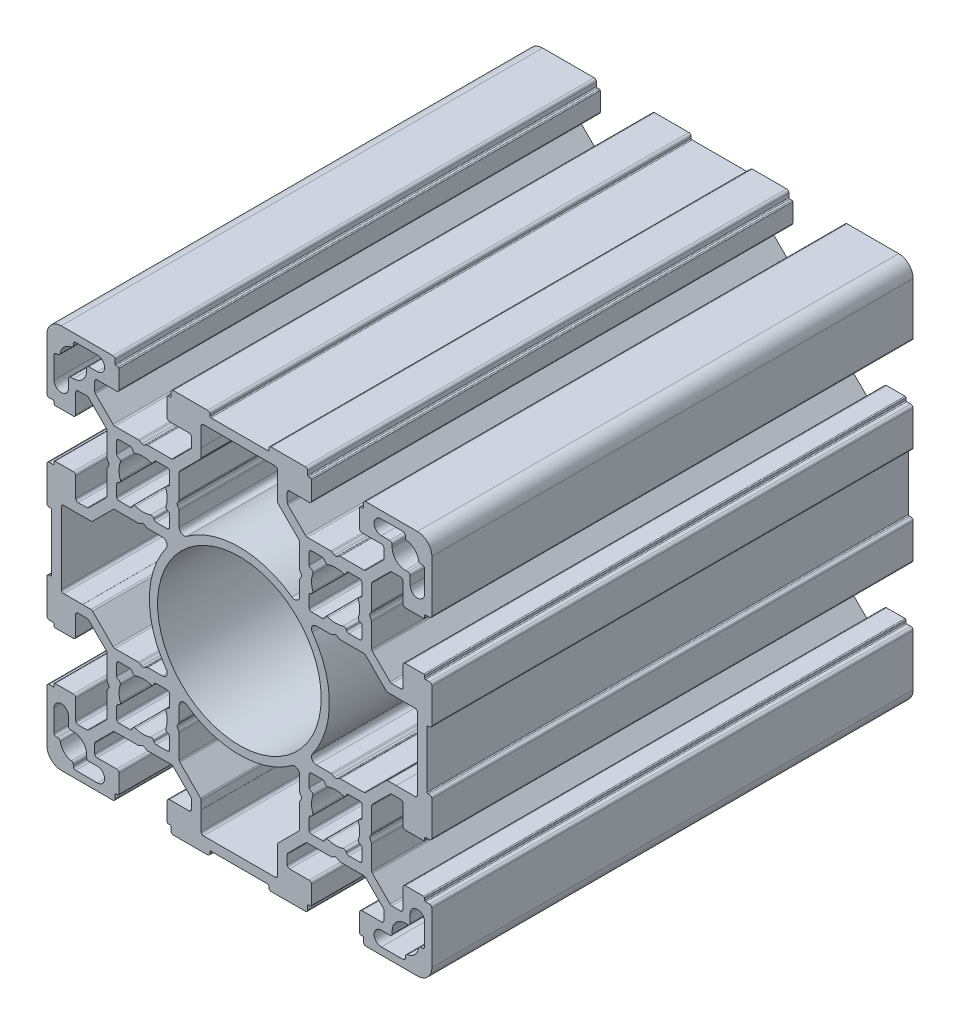
from build123d import *

# Parameters (mm, degrees)
SKETCH_1_R      = 17
EXTRUDE_2_DEPTH = 100


with BuildPart() as part:
    # Эскиз1 → Бобышка-Вытянуть2 (new body)
    with BuildSketch(Plane.XY):
        with BuildLine():
            Line((19.10095497, 46.510086301), (19.60095497, 46.798761436))
            ThreePointArc((19.60095497, 46.798761436), (19.721545448, 46.848711647), (19.85095497, 46.865748734))
            Line((19.85095497, 46.865748734), (24.729634627, 46.865748734))
            ThreePointArc((24.729634627, 46.865748734), (24.920976343, 46.903808968), (25.083188017, 47.012195343))
            Line((25.083188017, 47.012195343), (28.754508361, 50.683515687))
            ThreePointArc((28.754508361, 50.683515687), (28.862894737, 50.845727361), (28.90095497, 51.037069077))
            Line((28.90095497, 51.037069077), (28.90095497, 52.865748734))
            ThreePointArc((28.90095497, 52.865748734), (28.754508361, 53.219302125), (28.40095497, 53.365748734))
            Line((28.40095497, 53.365748734), (24.35095497, 53.365748734))
            ThreePointArc((24.35095497, 53.365748734), (23.99740158, 53.512195343), (23.85095497, 53.865748734))
            Line((23.85095497, 53.865748734), (23.85095497, 57.665748734))
            ThreePointArc((23.85095497, 57.665748734), (23.909533614, 57.80717009), (24.05095497, 57.865748734))
            Line((24.05095497, 57.865748734), (24.45095497, 57.865748734))
            ThreePointArc((24.45095497, 57.865748734), (24.592376327, 57.924327378), (24.65095497, 58.065748734))
            Line((24.65095497, 58.065748734), (24.65095497, 58.865748734))
            ThreePointArc((24.65095497, 58.865748734), (24.79740158, 59.219302125), (25.15095497, 59.365748734))
            Line((25.15095497, 59.365748734), (32.24095497, 59.365748734))
            ThreePointArc((32.24095497, 59.365748734), (32.594508361, 59.219302125), (32.74095497, 58.865748734))
            Line((32.74095497, 58.865748734), (32.74095497, 58.565748734))
            ThreePointArc((32.74095497, 58.565748734), (32.799533614, 58.424327378), (32.94095497, 58.365748734))
            Line((32.94095497, 58.365748734), (44.76095497, 58.365748734))
            ThreePointArc((44.76095497, 58.365748734), (44.902376327, 58.424327378), (44.96095497, 58.565748734))
            Line((44.96095497, 58.565748734), (44.96095497, 58.865748734))
            ThreePointArc((44.96095497, 58.865748734), (45.10740158, 59.219302125), (45.46095497, 59.365748734))
            Line((45.46095497, 59.365748734), (52.55095497, 59.365748734))
            ThreePointArc((52.55095497, 59.365748734), (52.904508361, 59.219302125), (53.05095497, 58.865748734))
            Line((53.05095497, 58.865748734), (53.05095497, 58.065748734))
            ThreePointArc((53.05095497, 58.065748734), (53.109533614, 57.924327378), (53.25095497, 57.865748734))
            Line((53.25095497, 57.865748734), (53.65095497, 57.865748734))
            ThreePointArc((53.65095497, 57.865748734), (53.792376327, 57.80717009), (53.85095497, 57.665748734))
            Line((53.85095497, 57.665748734), (53.85095497, 53.865748734))
            ThreePointArc((53.85095497, 53.865748734), (53.704508361, 53.512195343), (53.35095497, 53.365748734))
            Line((53.35095497, 53.365748734), (49.30095497, 53.365748734))
            ThreePointArc((49.30095497, 53.365748734), (48.94740158, 53.219302125), (48.80095497, 52.865748734))
            Line((48.80095497, 52.865748734), (48.80095497, 51.037069077))
            ThreePointArc((48.80095497, 51.037069077), (48.839015204, 50.845727361), (48.94740158, 50.683515687))
            Line((48.94740158, 50.683515687), (52.618721923, 47.012195343))
            ThreePointArc((52.618721923, 47.012195343), (52.780933598, 46.903808968), (52.972275314, 46.865748734))
            Line((52.972275314, 46.865748734), (57.85095497, 46.865748734))
            ThreePointArc((57.85095497, 46.865748734), (57.980364493, 46.848711647), (58.10095497, 46.798761436))
            Line((58.10095497, 46.798761436), (58.60095497, 46.510086301))
            ThreePointArc((58.60095497, 46.510086301), (58.85095497, 46.443099003), (59.10095497, 46.510086301))
            Line((59.10095497, 46.510086301), (59.60095497, 46.798761436))
            ThreePointArc((59.60095497, 46.798761436), (59.721545448, 46.848711647), (59.85095497, 46.865748734))
            Line((59.85095497, 46.865748734), (64.729634627, 46.865748734))
            ThreePointArc((64.729634627, 46.865748734), (64.920976343, 46.903808968), (65.083188017, 47.012195343))
            Line((65.083188017, 47.012195343), (68.754508361, 50.683515687))
            ThreePointArc((68.754508361, 50.683515687), (68.862894737, 50.845727361), (68.90095497, 51.037069077))
            Line((68.90095497, 51.037069077), (68.90095497, 52.865748734))
            ThreePointArc((68.90095497, 52.865748734), (68.754508361, 53.219302125), (68.40095497, 53.365748734))
            Line((68.40095497, 53.365748734), (64.35095497, 53.365748734))
            ThreePointArc((64.35095497, 53.365748734), (63.99740158, 53.512195343), (63.85095497, 53.865748734))
            Line((63.85095497, 53.865748734), (63.85095497, 57.665748734))
            ThreePointArc((63.85095497, 57.665748734), (63.909533614, 57.80717009), (64.05095497, 57.865748734))
            Line((64.05095497, 57.865748734), (64.45095497, 57.865748734))
            ThreePointArc((64.45095497, 57.865748734), (64.592376327, 57.924327378), (64.65095497, 58.065748734))
            Line((64.65095497, 58.065748734), (64.65095497, 58.865748734))
            ThreePointArc((64.65095497, 58.865748734), (64.79740158, 59.219302125), (65.15095497, 59.365748734))
            Line((65.15095497, 59.365748734), (75.85095497, 59.365748734))
            ThreePointArc((75.85095497, 59.365748734), (77.972275314, 58.487069077), (78.85095497, 56.365748734))
            Line((78.85095497, 56.365748734), (78.85095497, 45.665748734))
            ThreePointArc((78.85095497, 45.665748734), (78.704508361, 45.312195343), (78.35095497, 45.165748734))
            Line((78.35095497, 45.165748734), (77.55095497, 45.165748734))
            ThreePointArc((77.55095497, 45.165748734), (77.409533614, 45.10717009), (77.35095497, 44.965748734))
            Line((77.35095497, 44.965748734), (77.35095497, 44.565748734))
            ThreePointArc((77.35095497, 44.565748734), (77.292376327, 44.424327378), (77.15095497, 44.365748734))
            Line((77.15095497, 44.365748734), (73.35095497, 44.365748734))
            ThreePointArc((73.35095497, 44.365748734), (72.99740158, 44.512195343), (72.85095497, 44.865748734))
            Line((72.85095497, 44.865748734), (72.85095497, 48.915748734))
            ThreePointArc((72.85095497, 48.915748734), (72.704508361, 49.269302125), (72.35095497, 49.415748734))
            Line((72.35095497, 49.415748734), (70.522275314, 49.415748734))
            ThreePointArc((70.522275314, 49.415748734), (70.330933598, 49.3776885), (70.168721923, 49.269302125))
            Line((70.168721923, 49.269302125), (66.49740158, 45.597981781))
            ThreePointArc((66.49740158, 45.597981781), (66.389015204, 45.435770107), (66.35095497, 45.24442839))
            Line((66.35095497, 45.24442839), (66.35095497, 40.365748734))
            ThreePointArc((66.35095497, 40.365748734), (66.333917884, 40.236339211), (66.283967672, 40.115748734))
            Line((66.283967672, 40.115748734), (65.995292538, 39.615748734))
            ThreePointArc((65.995292538, 39.615748734), (65.92830524, 39.365748734), (65.995292538, 39.115748734))
            Line((65.995292538, 39.115748734), (66.283967672, 38.615748734))
            ThreePointArc((66.283967672, 38.615748734), (66.333917884, 38.495158256), (66.35095497, 38.365748734))
            Line((66.35095497, 38.365748734), (66.35095497, 33.487069077))
            ThreePointArc((66.35095497, 33.487069077), (66.389015204, 33.295727361), (66.49740158, 33.133515687))
            Line((66.49740158, 33.133515687), (70.168721923, 29.462195343))
            ThreePointArc((70.168721923, 29.462195343), (70.330933598, 29.353808968), (70.522275314, 29.315748734))
            Line((70.522275314, 29.315748734), (72.35095497, 29.315748734))
            ThreePointArc((72.35095497, 29.315748734), (72.704508361, 29.462195343), (72.85095497, 29.815748734))
            Line((72.85095497, 29.815748734), (72.85095497, 33.865748734))
            ThreePointArc((72.85095497, 33.865748734), (72.99740158, 34.219302125), (73.35095497, 34.365748734))
            Line((73.35095497, 34.365748734), (77.15095497, 34.365748734))
            ThreePointArc((77.15095497, 34.365748734), (77.292376327, 34.30717009), (77.35095497, 34.165748734))
            Line((77.35095497, 34.165748734), (77.35095497, 33.765748734))
            ThreePointArc((77.35095497, 33.765748734), (77.409533614, 33.624327378), (77.55095497, 33.565748734))
            Line((77.55095497, 33.565748734), (78.35095497, 33.565748734))
            ThreePointArc((78.35095497, 33.565748734), (78.704508361, 33.419302125), (78.85095497, 33.065748734))
            Line((78.85095497, 33.065748734), (78.85095497, 25.975748734))
            ThreePointArc((78.85095497, 25.975748734), (78.704508361, 25.622195343), (78.35095497, 25.475748734))
            Line((78.35095497, 25.475748734), (78.05095497, 25.475748734))
            ThreePointArc((78.05095497, 25.475748734), (77.909533614, 25.41717009), (77.85095497, 25.275748734))
            Line((77.85095497, 25.275748734), (77.85095497, 13.455748734))
            ThreePointArc((77.85095497, 13.455748734), (77.909533614, 13.314327378), (78.05095497, 13.255748734))
            Line((78.05095497, 13.255748734), (78.35095497, 13.255748734))
            ThreePointArc((78.35095497, 13.255748734), (78.704508361, 13.109302125), (78.85095497, 12.755748734))
            Line((78.85095497, 12.755748734), (78.85095497, 5.665748734))
            ThreePointArc((78.85095497, 5.665748734), (78.704508361, 5.312195343), (78.35095497, 5.165748734))
            Line((78.35095497, 5.165748734), (77.55095497, 5.165748734))
            ThreePointArc((77.55095497, 5.165748734), (77.409533614, 5.10717009), (77.35095497, 4.965748734))
            Line((77.35095497, 4.965748734), (77.35095497, 4.565748734))
            ThreePointArc((77.35095497, 4.565748734), (77.292376327, 4.424327378), (77.15095497, 4.365748734))
            Line((77.15095497, 4.365748734), (73.35095497, 4.365748734))
            ThreePointArc((73.35095497, 4.365748734), (72.99740158, 4.512195343), (72.85095497, 4.865748734))
            Line((72.85095497, 4.865748734), (72.85095497, 8.915748734))
            ThreePointArc((72.85095497, 8.915748734), (72.704508361, 9.269302125), (72.35095497, 9.415748734))
            Line((72.35095497, 9.415748734), (70.522275314, 9.415748734))
            ThreePointArc((70.522275314, 9.415748734), (70.330933598, 9.3776885), (70.168721923, 9.269302125))
            Line((70.168721923, 9.269302125), (66.49740158, 5.597981781))
            ThreePointArc((66.49740158, 5.597981781), (66.389015204, 5.435770107), (66.35095497, 5.24442839))
            Line((66.35095497, 5.24442839), (66.35095497, 0.365748734))
            ThreePointArc((66.35095497, 0.365748734), (66.333917884, 0.236339211), (66.283967672, 0.115748734))
            Line((66.283967672, 0.115748734), (65.995292538, -0.384251266))
            ThreePointArc((65.995292538, -0.384251266), (65.92830524, -0.634251266), (65.995292538, -0.884251266))
            Line((65.995292538, -0.884251266), (66.283967672, -1.384251266))
            ThreePointArc((66.283967672, -1.384251266), (66.333917884, -1.504841744), (66.35095497, -1.634251266))
            Line((66.35095497, -1.634251266), (66.35095497, -6.512930923))
            ThreePointArc((66.35095497, -6.512930923), (66.389015204, -6.704272639), (66.49740158, -6.866484313))
            Line((66.49740158, -6.866484313), (70.168721923, -10.537804657))
            ThreePointArc((70.168721923, -10.537804657), (70.330933598, -10.646191032), (70.522275314, -10.684251266))
            Line((70.522275314, -10.684251266), (72.35095497, -10.684251266))
            ThreePointArc((72.35095497, -10.684251266), (72.704508361, -10.537804657), (72.85095497, -10.184251266))
            Line((72.85095497, -10.184251266), (72.85095497, -6.134251266))
            ThreePointArc((72.85095497, -6.134251266), (72.99740158, -5.780697875), (73.35095497, -5.634251266))
            Line((73.35095497, -5.634251266), (77.15095497, -5.634251266))
            ThreePointArc((77.15095497, -5.634251266), (77.292376327, -5.69282991), (77.35095497, -5.834251266))
            Line((77.35095497, -5.834251266), (77.35095497, -6.234251266))
            ThreePointArc((77.35095497, -6.234251266), (77.409533614, -6.375672622), (77.55095497, -6.434251266))
            Line((77.55095497, -6.434251266), (78.35095497, -6.434251266))
            ThreePointArc((78.35095497, -6.434251266), (78.704508361, -6.580697875), (78.85095497, -6.934251266))
            Line((78.85095497, -6.934251266), (78.85095497, -17.634251266))
            ThreePointArc((78.85095497, -17.634251266), (77.972275314, -19.75557161), (75.85095497, -20.634251266))
            Line((75.85095497, -20.634251266), (65.15095497, -20.634251266))
            ThreePointArc((65.15095497, -20.634251266), (64.79740158, -20.487804657), (64.65095497, -20.134251266))
            Line((64.65095497, -20.134251266), (64.65095497, -19.334251266))
            ThreePointArc((64.65095497, -19.334251266), (64.592376327, -19.19282991), (64.45095497, -19.134251266))
            Line((64.45095497, -19.134251266), (64.05095497, -19.134251266))
            ThreePointArc((64.05095497, -19.134251266), (63.909533614, -19.075672622), (63.85095497, -18.934251266))
            Line((63.85095497, -18.934251266), (63.85095497, -15.134251266))
            ThreePointArc((63.85095497, -15.134251266), (63.99740158, -14.780697875), (64.35095497, -14.634251266))
            Line((64.35095497, -14.634251266), (68.40095497, -14.634251266))
            ThreePointArc((68.40095497, -14.634251266), (68.754508361, -14.487804657), (68.90095497, -14.134251266))
            Line((68.90095497, -14.134251266), (68.90095497, -12.30557161))
            ThreePointArc((68.90095497, -12.30557161), (68.862894737, -12.114229893), (68.754508361, -11.952018219))
            Line((68.754508361, -11.952018219), (65.083188017, -8.280697875))
            ThreePointArc((65.083188017, -8.280697875), (64.920976343, -8.1723115), (64.729634627, -8.134251266))
            Line((64.729634627, -8.134251266), (59.85095497, -8.134251266))
            ThreePointArc((59.85095497, -8.134251266), (59.721545448, -8.117214179), (59.60095497, -8.067263968))
            Line((59.60095497, -8.067263968), (59.10095497, -7.778588833))
            ThreePointArc((59.10095497, -7.778588833), (58.85095497, -7.711601535), (58.60095497, -7.778588833))
            Line((58.60095497, -7.778588833), (58.10095497, -8.067263968))
            ThreePointArc((58.10095497, -8.067263968), (57.980364493, -8.117214179), (57.85095497, -8.134251266))
            Line((57.85095497, -8.134251266), (52.972275314, -8.134251266))
            ThreePointArc((52.972275314, -8.134251266), (52.780933598, -8.1723115), (52.618721923, -8.280697875))
            Line((52.618721923, -8.280697875), (48.94740158, -11.952018219))
            ThreePointArc((48.94740158, -11.952018219), (48.839015204, -12.114229893), (48.80095497, -12.30557161))
            Line((48.80095497, -12.30557161), (48.80095497, -14.134251266))
            ThreePointArc((48.80095497, -14.134251266), (48.94740158, -14.487804657), (49.30095497, -14.634251266))
            Line((49.30095497, -14.634251266), (53.35095497, -14.634251266))
            ThreePointArc((53.35095497, -14.634251266), (53.704508361, -14.780697875), (53.85095497, -15.134251266))
            Line((53.85095497, -15.134251266), (53.85095497, -18.934251266))
            ThreePointArc((53.85095497, -18.934251266), (53.792376327, -19.075672622), (53.65095497, -19.134251266))
            Line((53.65095497, -19.134251266), (53.25095497, -19.134251266))
            ThreePointArc((53.25095497, -19.134251266), (53.109533614, -19.19282991), (53.05095497, -19.334251266))
            Line((53.05095497, -19.334251266), (53.05095497, -20.134251266))
            ThreePointArc((53.05095497, -20.134251266), (52.904508361, -20.487804657), (52.55095497, -20.634251266))
            Line((52.55095497, -20.634251266), (45.46095497, -20.634251266))
            ThreePointArc((45.46095497, -20.634251266), (45.10740158, -20.487804657), (44.96095497, -20.134251266))
            Line((44.96095497, -20.134251266), (44.96095497, -19.834251266))
            ThreePointArc((44.96095497, -19.834251266), (44.902376327, -19.69282991), (44.76095497, -19.634251266))
            Line((44.76095497, -19.634251266), (32.94095497, -19.634251266))
            ThreePointArc((32.94095497, -19.634251266), (32.799533614, -19.69282991), (32.74095497, -19.834251266))
            Line((32.74095497, -19.834251266), (32.74095497, -20.134251266))
            ThreePointArc((32.74095497, -20.134251266), (32.594508361, -20.487804657), (32.24095497, -20.634251266))
            Line((32.24095497, -20.634251266), (25.15095497, -20.634251266))
            ThreePointArc((25.15095497, -20.634251266), (24.79740158, -20.487804657), (24.65095497, -20.134251266))
            Line((24.65095497, -20.134251266), (24.65095497, -19.334251266))
            ThreePointArc((24.65095497, -19.334251266), (24.592376327, -19.19282991), (24.45095497, -19.134251266))
            Line((24.45095497, -19.134251266), (24.05095497, -19.134251266))
            ThreePointArc((24.05095497, -19.134251266), (23.909533614, -19.075672622), (23.85095497, -18.934251266))
            Line((23.85095497, -18.934251266), (23.85095497, -15.134251266))
            ThreePointArc((23.85095497, -15.134251266), (23.99740158, -14.780697875), (24.35095497, -14.634251266))
            Line((24.35095497, -14.634251266), (28.40095497, -14.634251266))
            ThreePointArc((28.40095497, -14.634251266), (28.754508361, -14.487804657), (28.90095497, -14.134251266))
            Line((28.90095497, -14.134251266), (28.90095497, -12.30557161))
            ThreePointArc((28.90095497, -12.30557161), (28.862894737, -12.114229893), (28.754508361, -11.952018219))
            Line((28.754508361, -11.952018219), (25.083188017, -8.280697875))
            ThreePointArc((25.083188017, -8.280697875), (24.920976343, -8.1723115), (24.729634627, -8.134251266))
            Line((24.729634627, -8.134251266), (19.85095497, -8.134251266))
            ThreePointArc((19.85095497, -8.134251266), (19.721545448, -8.117214179), (19.60095497, -8.067263968))
            Line((19.60095497, -8.067263968), (19.10095497, -7.778588833))
            ThreePointArc((19.10095497, -7.778588833), (18.85095497, -7.711601535), (18.60095497, -7.778588833))
            Line((18.60095497, -7.778588833), (18.10095497, -8.067263968))
            ThreePointArc((18.10095497, -8.067263968), (17.980364493, -8.117214179), (17.85095497, -8.134251266))
            Line((17.85095497, -8.134251266), (12.972275314, -8.134251266))
            ThreePointArc((12.972275314, -8.134251266), (12.780933598, -8.1723115), (12.618721923, -8.280697875))
            Line((12.618721923, -8.280697875), (8.94740158, -11.952018219))
            ThreePointArc((8.94740158, -11.952018219), (8.839015204, -12.114229893), (8.80095497, -12.30557161))
            Line((8.80095497, -12.30557161), (8.80095497, -14.134251266))
            ThreePointArc((8.80095497, -14.134251266), (8.94740158, -14.487804657), (9.30095497, -14.634251266))
            Line((9.30095497, -14.634251266), (13.35095497, -14.634251266))
            ThreePointArc((13.35095497, -14.634251266), (13.704508361, -14.780697875), (13.85095497, -15.134251266))
            Line((13.85095497, -15.134251266), (13.85095497, -18.934251266))
            ThreePointArc((13.85095497, -18.934251266), (13.792376327, -19.075672622), (13.65095497, -19.134251266))
            Line((13.65095497, -19.134251266), (13.25095497, -19.134251266))
            ThreePointArc((13.25095497, -19.134251266), (13.109533614, -19.19282991), (13.05095497, -19.334251266))
            Line((13.05095497, -19.334251266), (13.05095497, -20.134251266))
            ThreePointArc((13.05095497, -20.134251266), (12.904508361, -20.487804657), (12.55095497, -20.634251266))
            Line((12.55095497, -20.634251266), (1.85095497, -20.634251266))
            ThreePointArc((1.85095497, -20.634251266), (-0.270365373, -19.75557161), (-1.14904503, -17.634251266))
            Line((-1.14904503, -17.634251266), (-1.14904503, -6.934251266))
            ThreePointArc((-1.14904503, -6.934251266), (-1.00259842, -6.580697875), (-0.64904503, -6.434251266))
            Line((-0.64904503, -6.434251266), (0.15095497, -6.434251266))
            ThreePointArc((0.15095497, -6.434251266), (0.292376327, -6.375672622), (0.35095497, -6.234251266))
            Line((0.35095497, -6.234251266), (0.35095497, -5.834251266))
            ThreePointArc((0.35095497, -5.834251266), (0.409533614, -5.69282991), (0.55095497, -5.634251266))
            Line((0.55095497, -5.634251266), (4.35095497, -5.634251266))
            ThreePointArc((4.35095497, -5.634251266), (4.704508361, -5.780697875), (4.85095497, -6.134251266))
            Line((4.85095497, -6.134251266), (4.85095497, -10.184251266))
            ThreePointArc((4.85095497, -10.184251266), (4.99740158, -10.537804657), (5.35095497, -10.684251266))
            Line((5.35095497, -10.684251266), (7.179634627, -10.684251266))
            ThreePointArc((7.179634627, -10.684251266), (7.370976343, -10.646191032), (7.533188017, -10.537804657))
            Line((7.533188017, -10.537804657), (11.204508361, -6.866484313))
            ThreePointArc((11.204508361, -6.866484313), (11.312894737, -6.704272639), (11.35095497, -6.512930923))
            Line((11.35095497, -6.512930923), (11.35095497, -1.634251266))
            ThreePointArc((11.35095497, -1.634251266), (11.367992057, -1.504841744), (11.417942269, -1.384251266))
            Line((11.417942269, -1.384251266), (11.706617403, -0.884251266))
            ThreePointArc((11.706617403, -0.884251266), (11.773604701, -0.634251266), (11.706617403, -0.384251266))
            Line((11.706617403, -0.384251266), (11.417942269, 0.115748734))
            ThreePointArc((11.417942269, 0.115748734), (11.367992057, 0.236339211), (11.35095497, 0.365748734))
            Line((11.35095497, 0.365748734), (11.35095497, 5.24442839))
            ThreePointArc((11.35095497, 5.24442839), (11.312894737, 5.435770107), (11.204508361, 5.597981781))
            Line((11.204508361, 5.597981781), (7.533188017, 9.269302125))
            ThreePointArc((7.533188017, 9.269302125), (7.370976343, 9.3776885), (7.179634627, 9.415748734))
            Line((7.179634627, 9.415748734), (5.35095497, 9.415748734))
            ThreePointArc((5.35095497, 9.415748734), (4.99740158, 9.269302125), (4.85095497, 8.915748734))
            Line((4.85095497, 8.915748734), (4.85095497, 4.865748734))
            ThreePointArc((4.85095497, 4.865748734), (4.704508361, 4.512195343), (4.35095497, 4.365748734))
            Line((4.35095497, 4.365748734), (0.55095497, 4.365748734))
            ThreePointArc((0.55095497, 4.365748734), (0.409533614, 4.424327378), (0.35095497, 4.565748734))
            Line((0.35095497, 4.565748734), (0.35095497, 4.965748734))
            ThreePointArc((0.35095497, 4.965748734), (0.292376327, 5.10717009), (0.15095497, 5.165748734))
            Line((0.15095497, 5.165748734), (-0.64904503, 5.165748734))
            ThreePointArc((-0.64904503, 5.165748734), (-1.00259842, 5.312195343), (-1.14904503, 5.665748734))
            Line((-1.14904503, 5.665748734), (-1.14904503, 12.755748734))
            ThreePointArc((-1.14904503, 12.755748734), (-1.00259842, 13.109302125), (-0.64904503, 13.255748734))
            Line((-0.64904503, 13.255748734), (-0.34904503, 13.255748734))
            ThreePointArc((-0.34904503, 13.255748734), (-0.207623673, 13.314327378), (-0.14904503, 13.455748734))
            Line((-0.14904503, 13.455748734), (-0.14904503, 25.275748734))
            ThreePointArc((-0.14904503, 25.275748734), (-0.207623673, 25.41717009), (-0.34904503, 25.475748734))
            Line((-0.34904503, 25.475748734), (-0.64904503, 25.475748734))
            ThreePointArc((-0.64904503, 25.475748734), (-1.00259842, 25.622195343), (-1.14904503, 25.975748734))
            Line((-1.14904503, 25.975748734), (-1.14904503, 33.065748734))
            ThreePointArc((-1.14904503, 33.065748734), (-1.00259842, 33.419302125), (-0.64904503, 33.565748734))
            Line((-0.64904503, 33.565748734), (0.15095497, 33.565748734))
            ThreePointArc((0.15095497, 33.565748734), (0.292376327, 33.624327378), (0.35095497, 33.765748734))
            Line((0.35095497, 33.765748734), (0.35095497, 34.165748734))
            ThreePointArc((0.35095497, 34.165748734), (0.409533614, 34.30717009), (0.55095497, 34.365748734))
            Line((0.55095497, 34.365748734), (4.35095497, 34.365748734))
            ThreePointArc((4.35095497, 34.365748734), (4.704508361, 34.219302125), (4.85095497, 33.865748734))
            Line((4.85095497, 33.865748734), (4.85095497, 29.815748734))
            ThreePointArc((4.85095497, 29.815748734), (4.99740158, 29.462195343), (5.35095497, 29.315748734))
            Line((5.35095497, 29.315748734), (7.179634627, 29.315748734))
            ThreePointArc((7.179634627, 29.315748734), (7.370976343, 29.353808968), (7.533188017, 29.462195343))
            Line((7.533188017, 29.462195343), (11.204508361, 33.133515687))
            ThreePointArc((11.204508361, 33.133515687), (11.312894737, 33.295727361), (11.35095497, 33.487069077))
            Line((11.35095497, 33.487069077), (11.35095497, 38.365748734))
            ThreePointArc((11.35095497, 38.365748734), (11.367992057, 38.495158256), (11.417942269, 38.615748734))
            Line((11.417942269, 38.615748734), (11.706617403, 39.115748734))
            ThreePointArc((11.706617403, 39.115748734), (11.773604701, 39.365748734), (11.706617403, 39.615748734))
            Line((11.706617403, 39.615748734), (11.417942269, 40.115748734))
            ThreePointArc((11.417942269, 40.115748734), (11.367992057, 40.236339211), (11.35095497, 40.365748734))
            Line((11.35095497, 40.365748734), (11.35095497, 45.24442839))
            ThreePointArc((11.35095497, 45.24442839), (11.312894737, 45.435770107), (11.204508361, 45.597981781))
            Line((11.204508361, 45.597981781), (7.533188017, 49.269302125))
            ThreePointArc((7.533188017, 49.269302125), (7.370976343, 49.3776885), (7.179634627, 49.415748734))
            Line((7.179634627, 49.415748734), (5.35095497, 49.415748734))
            ThreePointArc((5.35095497, 49.415748734), (4.99740158, 49.269302125), (4.85095497, 48.915748734))
            Line((4.85095497, 48.915748734), (4.85095497, 44.865748734))
            ThreePointArc((4.85095497, 44.865748734), (4.704508361, 44.512195343), (4.35095497, 44.365748734))
            Line((4.35095497, 44.365748734), (0.55095497, 44.365748734))
            ThreePointArc((0.55095497, 44.365748734), (0.409533614, 44.424327378), (0.35095497, 44.565748734))
            Line((0.35095497, 44.565748734), (0.35095497, 44.965748734))
            ThreePointArc((0.35095497, 44.965748734), (0.292376327, 45.10717009), (0.15095497, 45.165748734))
            Line((0.15095497, 45.165748734), (-0.64904503, 45.165748734))
            ThreePointArc((-0.64904503, 45.165748734), (-1.00259842, 45.312195343), (-1.14904503, 45.665748734))
            Line((-1.14904503, 45.665748734), (-1.14904503, 56.365748734))
            ThreePointArc((-1.14904503, 56.365748734), (-0.270365373, 58.487069077), (1.85095497, 59.365748734))
            Line((1.85095497, 59.365748734), (12.55095497, 59.365748734))
            ThreePointArc((12.55095497, 59.365748734), (12.904508361, 59.219302125), (13.05095497, 58.865748734))
            Line((13.05095497, 58.865748734), (13.05095497, 58.065748734))
            ThreePointArc((13.05095497, 58.065748734), (13.109533614, 57.924327378), (13.25095497, 57.865748734))
            Line((13.25095497, 57.865748734), (13.65095497, 57.865748734))
            ThreePointArc((13.65095497, 57.865748734), (13.792376327, 57.80717009), (13.85095497, 57.665748734))
            Line((13.85095497, 57.665748734), (13.85095497, 53.865748734))
            ThreePointArc((13.85095497, 53.865748734), (13.704508361, 53.512195343), (13.35095497, 53.365748734))
            Line((13.35095497, 53.365748734), (9.30095497, 53.365748734))
            ThreePointArc((9.30095497, 53.365748734), (8.94740158, 53.219302125), (8.80095497, 52.865748734))
            Line((8.80095497, 52.865748734), (8.80095497, 51.037069077))
            ThreePointArc((8.80095497, 51.037069077), (8.839015204, 50.845727361), (8.94740158, 50.683515687))
            Line((8.94740158, 50.683515687), (12.618721923, 47.012195343))
            ThreePointArc((12.618721923, 47.012195343), (12.780933598, 46.903808968), (12.972275314, 46.865748734))
            Line((12.972275314, 46.865748734), (17.85095497, 46.865748734))
            ThreePointArc((17.85095497, 46.865748734), (17.980364493, 46.848711647), (18.10095497, 46.798761436))
            Line((18.10095497, 46.798761436), (18.60095497, 46.510086301))
            ThreePointArc((18.60095497, 46.510086301), (18.85095497, 46.443099003), (19.10095497, 46.510086301))
        make_face()
        with Locations((38.85095497, 19.365748734)):
            Circle(SKETCH_1_R, mode=Mode.SUBTRACT)
        with BuildLine():
            Line((4.35095497, 57.365748734), (4.35095497, 57.077056879))
            ThreePointArc((4.35095497, 57.077056879), (4.230732233, 56.751835061), (3.927878047, 56.583009472))
            ThreePointArc((3.927878047, 56.583009472), (2.406411322, 55.810292382), (1.633694233, 54.288825657))
            ThreePointArc((1.633694233, 54.288825657), (1.464868644, 53.985971471), (1.139646826, 53.865748734))
            Line((1.139646826, 53.865748734), (0.85095497, 53.865748734))
            ThreePointArc((0.85095497, 53.865748734), (0.49740158, 53.719302125), (0.35095497, 53.365748734))
            Line((0.35095497, 53.365748734), (0.35095497, 48.865748734))
            ThreePointArc((0.35095497, 48.865748734), (1.85095497, 47.365748734), (3.35095497, 48.865748734))
            Line((3.35095497, 48.865748734), (3.35095497, 50.615748734))
            ThreePointArc((3.35095497, 50.615748734), (3.49740158, 50.969302125), (3.85095497, 51.115748734))
            Line((3.85095497, 51.115748734), (4.35095497, 51.115748734))
            ThreePointArc((4.35095497, 51.115748734), (6.295498619, 51.921205086), (7.10095497, 53.865748734))
            Line((7.10095497, 53.865748734), (7.10095497, 54.365748734))
            ThreePointArc((7.10095497, 54.365748734), (7.24740158, 54.719302125), (7.60095497, 54.865748734))
            Line((7.60095497, 54.865748734), (9.35095497, 54.865748734))
            ThreePointArc((9.35095497, 54.865748734), (10.85095497, 56.365748734), (9.35095497, 57.865748734))
            Line((9.35095497, 57.865748734), (4.85095497, 57.865748734))
            ThreePointArc((4.85095497, 57.865748734), (4.49740158, 57.719302125), (4.35095497, 57.365748734))
        make_face(mode=Mode.SUBTRACT)
        with BuildLine():
            Line((19.85095497, 31.865748734), (22.855955752, 31.865748734))
            ThreePointArc((22.855955752, 31.865748734), (23.745831121, 31.321952447), (23.667884646, 30.281992389))
            ThreePointArc((23.667884646, 30.281992389), (20.15095497, 19.365748734), (23.667884646, 8.449505079))
            ThreePointArc((23.667884646, 8.449505079), (23.745831121, 7.409545021), (22.855955752, 6.865748734))
            Line((22.855955752, 6.865748734), (19.85095497, 6.865748734))
            ThreePointArc((19.85095497, 6.865748734), (19.721545448, 6.848711647), (19.60095497, 6.798761436))
            Line((19.60095497, 6.798761436), (19.10095497, 6.510086301))
            ThreePointArc((19.10095497, 6.510086301), (18.85095497, 6.443099003), (18.60095497, 6.510086301))
            Line((18.60095497, 6.510086301), (18.10095497, 6.798761436))
            ThreePointArc((18.10095497, 6.798761436), (17.980364493, 6.848711647), (17.85095497, 6.865748734))
            Line((17.85095497, 6.865748734), (12.972275314, 6.865748734))
            ThreePointArc((12.972275314, 6.865748734), (12.780933598, 6.903808968), (12.618721923, 7.012195343))
            Line((12.618721923, 7.012195343), (8.94740158, 10.683515687))
            Line((8.94740158, 10.683515687), (8.361615142, 11.269302125))
            ThreePointArc((8.361615142, 11.269302125), (8.199403468, 11.3776885), (8.008061752, 11.415748734))
            Line((8.008061752, 11.415748734), (6.265294799, 11.415748734))
            Line((6.265294799, 11.415748734), (6.270825406, 11.430739114))
            Line((6.270825406, 11.430739114), (2.352650755, 11.417450279))
            ThreePointArc((2.352650755, 11.417450279), (1.998001639, 11.56329497), (1.85095497, 11.917447404))
            Line((1.85095497, 11.917447404), (1.85095497, 26.814050064))
            ThreePointArc((1.85095497, 26.814050064), (1.998001639, 27.168202498), (2.352650755, 27.314047188))
            Line((2.352650755, 27.314047188), (6.270825406, 27.300758354))
            Line((6.270825406, 27.300758354), (6.265294799, 27.315748734))
            Line((6.265294799, 27.315748734), (8.008061752, 27.315748734))
            ThreePointArc((8.008061752, 27.315748734), (8.199403468, 27.353808968), (8.361615142, 27.462195343))
            Line((8.361615142, 27.462195343), (8.94740158, 28.047981781))
            Line((8.94740158, 28.047981781), (12.618721923, 31.719302125))
            ThreePointArc((12.618721923, 31.719302125), (12.780933598, 31.8276885), (12.972275314, 31.865748734))
            Line((12.972275314, 31.865748734), (17.85095497, 31.865748734))
            ThreePointArc((17.85095497, 31.865748734), (17.980364493, 31.882785821), (18.10095497, 31.932736032))
            Line((18.10095497, 31.932736032), (18.60095497, 32.221411167))
            ThreePointArc((18.60095497, 32.221411167), (18.85095497, 32.288398465), (19.10095497, 32.221411167))
            Line((19.10095497, 32.221411167), (19.60095497, 31.932736032))
            ThreePointArc((19.60095497, 31.932736032), (19.721545448, 31.882785821), (19.85095497, 31.865748734))
        make_face(mode=Mode.SUBTRACT)
        with BuildLine():
            Line((26.35095497, 38.365748734), (26.35095497, 35.360747952))
            ThreePointArc((26.35095497, 35.360747952), (26.894751258, 34.470872583), (27.934711316, 34.548819058))
            ThreePointArc((27.934711316, 34.548819058), (38.85095497, 38.065748734), (49.767198625, 34.548819058))
            ThreePointArc((49.767198625, 34.548819058), (50.807158683, 34.470872583), (51.35095497, 35.360747952))
            Line((51.35095497, 35.360747952), (51.35095497, 38.365748734))
            ThreePointArc((51.35095497, 38.365748734), (51.367992057, 38.495158256), (51.417942269, 38.615748734))
            Line((51.417942269, 38.615748734), (51.706617403, 39.115748734))
            ThreePointArc((51.706617403, 39.115748734), (51.773604701, 39.365748734), (51.706617403, 39.615748734))
            Line((51.706617403, 39.615748734), (51.417942269, 40.115748734))
            ThreePointArc((51.417942269, 40.115748734), (51.367992057, 40.236339211), (51.35095497, 40.365748734))
            Line((51.35095497, 40.365748734), (51.35095497, 45.24442839))
            ThreePointArc((51.35095497, 45.24442839), (51.312894737, 45.435770107), (51.204508361, 45.597981781))
            Line((51.204508361, 45.597981781), (47.533188017, 49.269302125))
            Line((47.533188017, 49.269302125), (46.94740158, 49.855088562))
            ThreePointArc((46.94740158, 49.855088562), (46.839015204, 50.017300237), (46.80095497, 50.208641953))
            Line((46.80095497, 50.208641953), (46.80095497, 51.951408906))
            Line((46.80095497, 51.951408906), (46.78596459, 51.945878298))
            Line((46.78596459, 51.945878298), (46.799253425, 55.86405295))
            ThreePointArc((46.799253425, 55.86405295), (46.653408734, 56.218702065), (46.299256301, 56.365748734))
            Line((46.299256301, 56.365748734), (31.40265364, 56.365748734))
            ThreePointArc((31.40265364, 56.365748734), (31.048501207, 56.218702065), (30.902656516, 55.86405295))
            Line((30.902656516, 55.86405295), (30.915945351, 51.945878298))
            Line((30.915945351, 51.945878298), (30.90095497, 51.951408906))
            Line((30.90095497, 51.951408906), (30.90095497, 50.208641953))
            ThreePointArc((30.90095497, 50.208641953), (30.862894737, 50.017300237), (30.754508361, 49.855088562))
            Line((30.754508361, 49.855088562), (30.168721923, 49.269302125))
            Line((30.168721923, 49.269302125), (26.49740158, 45.597981781))
            ThreePointArc((26.49740158, 45.597981781), (26.389015204, 45.435770107), (26.35095497, 45.24442839))
            Line((26.35095497, 45.24442839), (26.35095497, 40.365748734))
            ThreePointArc((26.35095497, 40.365748734), (26.333917884, 40.236339211), (26.283967672, 40.115748734))
            Line((26.283967672, 40.115748734), (25.995292538, 39.615748734))
            ThreePointArc((25.995292538, 39.615748734), (25.92830524, 39.365748734), (25.995292538, 39.115748734))
            Line((25.995292538, 39.115748734), (26.283967672, 38.615748734))
            ThreePointArc((26.283967672, 38.615748734), (26.333917884, 38.495158256), (26.35095497, 38.365748734))
        make_face(mode=Mode.SUBTRACT)
        with BuildLine():
            Line((54.845954189, 31.865748734), (57.85095497, 31.865748734))
            ThreePointArc((57.85095497, 31.865748734), (57.980364493, 31.882785821), (58.10095497, 31.932736032))
            Line((58.10095497, 31.932736032), (58.60095497, 32.221411167))
            ThreePointArc((58.60095497, 32.221411167), (58.85095497, 32.288398465), (59.10095497, 32.221411167))
            Line((59.10095497, 32.221411167), (59.60095497, 31.932736032))
            ThreePointArc((59.60095497, 31.932736032), (59.721545448, 31.882785821), (59.85095497, 31.865748734))
            Line((59.85095497, 31.865748734), (64.729634627, 31.865748734))
            ThreePointArc((64.729634627, 31.865748734), (64.920976343, 31.8276885), (65.083188017, 31.719302125))
            Line((65.083188017, 31.719302125), (68.754508361, 28.047981781))
            Line((68.754508361, 28.047981781), (69.340294799, 27.462195343))
            ThreePointArc((69.340294799, 27.462195343), (69.502506473, 27.353808968), (69.693848189, 27.315748734))
            Line((69.693848189, 27.315748734), (71.436615142, 27.315748734))
            Line((71.436615142, 27.315748734), (71.431084535, 27.300758354))
            Line((71.431084535, 27.300758354), (75.349259186, 27.314047188))
            ThreePointArc((75.349259186, 27.314047188), (75.703908302, 27.168202498), (75.85095497, 26.814050064))
            Line((75.85095497, 26.814050064), (75.85095497, 11.917447404))
            ThreePointArc((75.85095497, 11.917447404), (75.703908302, 11.56329497), (75.349259186, 11.417450279))
            Line((75.349259186, 11.417450279), (71.431084535, 11.430739114))
            Line((71.431084535, 11.430739114), (71.436615142, 11.415748734))
            Line((71.436615142, 11.415748734), (69.693848189, 11.415748734))
            ThreePointArc((69.693848189, 11.415748734), (69.502506473, 11.3776885), (69.340294799, 11.269302125))
            Line((69.340294799, 11.269302125), (68.754508361, 10.683515687))
            Line((68.754508361, 10.683515687), (65.083188017, 7.012195343))
            ThreePointArc((65.083188017, 7.012195343), (64.920976343, 6.903808968), (64.729634627, 6.865748734))
            Line((64.729634627, 6.865748734), (59.85095497, 6.865748734))
            ThreePointArc((59.85095497, 6.865748734), (59.721545448, 6.848711647), (59.60095497, 6.798761436))
            Line((59.60095497, 6.798761436), (59.10095497, 6.510086301))
            ThreePointArc((59.10095497, 6.510086301), (58.85095497, 6.443099003), (58.60095497, 6.510086301))
            Line((58.60095497, 6.510086301), (58.10095497, 6.798761436))
            ThreePointArc((58.10095497, 6.798761436), (57.980364493, 6.848711647), (57.85095497, 6.865748734))
            Line((57.85095497, 6.865748734), (54.845954189, 6.865748734))
            ThreePointArc((54.845954189, 6.865748734), (53.95607882, 7.409545021), (54.034025295, 8.449505079))
            ThreePointArc((54.034025295, 8.449505079), (57.55095497, 19.365748734), (54.034025295, 30.281992389))
            ThreePointArc((54.034025295, 30.281992389), (53.95607882, 31.321952447), (54.845954189, 31.865748734))
        make_face(mode=Mode.SUBTRACT)
        with BuildLine():
            Line((13.651580436, 41.635033061), (13.830480159, 41.557245248))
            ThreePointArc((13.830480159, 41.557245248), (14.087640111, 41.302617792), (14.105637384, 40.941172804))
            ThreePointArc((14.105637384, 40.941172804), (13.85095497, 39.365748734), (14.105637384, 37.790324664))
            ThreePointArc((14.105637384, 37.790324664), (14.087640111, 37.428879675), (13.830480159, 37.17425222))
            Line((13.830480159, 37.17425222), (13.651580436, 37.096464407))
            ThreePointArc((13.651580436, 37.096464407), (13.432811893, 36.912080984), (13.35095497, 36.637934369))
            Line((13.35095497, 36.637934369), (13.35095497, 34.365748734))
            ThreePointArc((13.35095497, 34.365748734), (13.49740158, 34.012195343), (13.85095497, 33.865748734))
            Line((13.85095497, 33.865748734), (16.123140606, 33.865748734))
            ThreePointArc((16.123140606, 33.865748734), (16.397287221, 33.947605656), (16.581670643, 34.166374199))
            Line((16.581670643, 34.166374199), (16.659458457, 34.345273923))
            ThreePointArc((16.659458457, 34.345273923), (16.914085912, 34.602433875), (17.275530901, 34.620431147))
            ThreePointArc((17.275530901, 34.620431147), (18.85095497, 34.365748734), (20.42637904, 34.620431147))
            ThreePointArc((20.42637904, 34.620431147), (20.787824029, 34.602433875), (21.042451484, 34.345273923))
            Line((21.042451484, 34.345273923), (21.120239298, 34.166374199))
            ThreePointArc((21.120239298, 34.166374199), (21.30462272, 33.947605656), (21.578769335, 33.865748734))
            Line((21.578769335, 33.865748734), (23.85095497, 33.865748734))
            ThreePointArc((23.85095497, 33.865748734), (24.204508361, 34.012195343), (24.35095497, 34.365748734))
            Line((24.35095497, 34.365748734), (24.35095497, 36.637934369))
            ThreePointArc((24.35095497, 36.637934369), (24.269098048, 36.912080984), (24.050329505, 37.096464407))
            Line((24.050329505, 37.096464407), (23.871429782, 37.17425222))
            ThreePointArc((23.871429782, 37.17425222), (23.61426983, 37.428879675), (23.596272557, 37.790324664))
            ThreePointArc((23.596272557, 37.790324664), (23.85095497, 39.365748734), (23.596272557, 40.941172804))
            ThreePointArc((23.596272557, 40.941172804), (23.61426983, 41.302617792), (23.871429782, 41.557245248))
            Line((23.871429782, 41.557245248), (24.050329505, 41.635033061))
            ThreePointArc((24.050329505, 41.635033061), (24.269098048, 41.819416484), (24.35095497, 42.093563098))
            Line((24.35095497, 42.093563098), (24.35095497, 44.365748734))
            ThreePointArc((24.35095497, 44.365748734), (24.204508361, 44.719302125), (23.85095497, 44.865748734))
            Line((23.85095497, 44.865748734), (21.578769335, 44.865748734))
            ThreePointArc((21.578769335, 44.865748734), (21.30462272, 44.783891812), (21.120239298, 44.565123268))
            Line((21.120239298, 44.565123268), (21.042451484, 44.386223545))
            ThreePointArc((21.042451484, 44.386223545), (20.787824029, 44.129063593), (20.42637904, 44.111066321))
            ThreePointArc((20.42637904, 44.111066321), (18.85095497, 44.365748734), (17.275530901, 44.111066321))
            ThreePointArc((17.275530901, 44.111066321), (16.914085912, 44.129063593), (16.659458457, 44.386223545))
            Line((16.659458457, 44.386223545), (16.581670643, 44.565123268))
            ThreePointArc((16.581670643, 44.565123268), (16.397287221, 44.783891812), (16.123140606, 44.865748734))
            Line((16.123140606, 44.865748734), (13.85095497, 44.865748734))
            ThreePointArc((13.85095497, 44.865748734), (13.49740158, 44.719302125), (13.35095497, 44.365748734))
            Line((13.35095497, 44.365748734), (13.35095497, 42.093563098))
            ThreePointArc((13.35095497, 42.093563098), (13.432811893, 41.819416484), (13.651580436, 41.635033061))
        make_face(mode=Mode.SUBTRACT)
        with BuildLine():
            Line((26.35095497, 3.370749515), (26.35095497, 0.365748734))
            ThreePointArc((26.35095497, 0.365748734), (26.333917884, 0.236339211), (26.283967672, 0.115748734))
            Line((26.283967672, 0.115748734), (25.995292538, -0.384251266))
            ThreePointArc((25.995292538, -0.384251266), (25.92830524, -0.634251266), (25.995292538, -0.884251266))
            Line((25.995292538, -0.884251266), (26.283967672, -1.384251266))
            ThreePointArc((26.283967672, -1.384251266), (26.333917884, -1.504841744), (26.35095497, -1.634251266))
            Line((26.35095497, -1.634251266), (26.35095497, -6.512930923))
            ThreePointArc((26.35095497, -6.512930923), (26.389015204, -6.704272639), (26.49740158, -6.866484313))
            Line((26.49740158, -6.866484313), (30.168721923, -10.537804657))
            Line((30.168721923, -10.537804657), (30.754508361, -11.123591094))
            ThreePointArc((30.754508361, -11.123591094), (30.862894737, -11.285802769), (30.90095497, -11.477144485))
            Line((30.90095497, -11.477144485), (30.90095497, -13.219911438))
            Line((30.90095497, -13.219911438), (30.915945351, -13.21438083))
            Line((30.915945351, -13.21438083), (30.902656516, -17.132555482))
            ThreePointArc((30.902656516, -17.132555482), (31.048501207, -17.487204597), (31.40265364, -17.634251266))
            Line((31.40265364, -17.634251266), (46.299256301, -17.634251266))
            ThreePointArc((46.299256301, -17.634251266), (46.653408734, -17.487204597), (46.799253425, -17.132555482))
            Line((46.799253425, -17.132555482), (46.78596459, -13.21438083))
            Line((46.78596459, -13.21438083), (46.80095497, -13.219911438))
            Line((46.80095497, -13.219911438), (46.80095497, -11.477144485))
            ThreePointArc((46.80095497, -11.477144485), (46.839015204, -11.285802769), (46.94740158, -11.123591094))
            Line((46.94740158, -11.123591094), (47.533188017, -10.537804657))
            Line((47.533188017, -10.537804657), (51.204508361, -6.866484313))
            ThreePointArc((51.204508361, -6.866484313), (51.312894737, -6.704272639), (51.35095497, -6.512930923))
            Line((51.35095497, -6.512930923), (51.35095497, -1.634251266))
            ThreePointArc((51.35095497, -1.634251266), (51.367992057, -1.504841744), (51.417942269, -1.384251266))
            Line((51.417942269, -1.384251266), (51.706617403, -0.884251266))
            ThreePointArc((51.706617403, -0.884251266), (51.773604701, -0.634251266), (51.706617403, -0.384251266))
            Line((51.706617403, -0.384251266), (51.417942269, 0.115748734))
            ThreePointArc((51.417942269, 0.115748734), (51.367992057, 0.236339211), (51.35095497, 0.365748734))
            Line((51.35095497, 0.365748734), (51.35095497, 3.370749515))
            ThreePointArc((51.35095497, 3.370749515), (50.807158683, 4.260624885), (49.767198625, 4.18267841))
            ThreePointArc((49.767198625, 4.18267841), (38.85095497, 0.665748734), (27.934711316, 4.18267841))
            ThreePointArc((27.934711316, 4.18267841), (26.894751258, 4.260624885), (26.35095497, 3.370749515))
        make_face(mode=Mode.SUBTRACT)
        with BuildLine():
            Line((0.85095497, -15.134251266), (1.139646826, -15.134251266))
            ThreePointArc((1.139646826, -15.134251266), (1.464868644, -15.254474003), (1.633694233, -15.557328189))
            ThreePointArc((1.633694233, -15.557328189), (2.406411322, -17.078794914), (3.927878047, -17.851512004))
            ThreePointArc((3.927878047, -17.851512004), (4.230732233, -18.020337593), (4.35095497, -18.345559411))
            Line((4.35095497, -18.345559411), (4.35095497, -18.634251266))
            ThreePointArc((4.35095497, -18.634251266), (4.49740158, -18.987804657), (4.85095497, -19.134251266))
            Line((4.85095497, -19.134251266), (9.35095497, -19.134251266))
            ThreePointArc((9.35095497, -19.134251266), (10.85095497, -17.634251266), (9.35095497, -16.134251266))
            Line((9.35095497, -16.134251266), (7.60095497, -16.134251266))
            ThreePointArc((7.60095497, -16.134251266), (7.24740158, -15.987804657), (7.10095497, -15.634251266))
            Line((7.10095497, -15.634251266), (7.10095497, -15.134251266))
            ThreePointArc((7.10095497, -15.134251266), (6.295498619, -13.189707618), (4.35095497, -12.384251266))
            Line((4.35095497, -12.384251266), (3.85095497, -12.384251266))
            ThreePointArc((3.85095497, -12.384251266), (3.49740158, -12.237804657), (3.35095497, -11.884251266))
            Line((3.35095497, -11.884251266), (3.35095497, -10.134251266))
            ThreePointArc((3.35095497, -10.134251266), (1.85095497, -8.634251266), (0.35095497, -10.134251266))
            Line((0.35095497, -10.134251266), (0.35095497, -14.634251266))
            ThreePointArc((0.35095497, -14.634251266), (0.49740158, -14.987804657), (0.85095497, -15.134251266))
        make_face(mode=Mode.SUBTRACT)
        with BuildLine():
            Line((16.581670643, -5.833625801), (16.659458457, -5.654726077))
            ThreePointArc((16.659458457, -5.654726077), (16.914085912, -5.397566125), (17.275530901, -5.379568853))
            ThreePointArc((17.275530901, -5.379568853), (18.85095497, -5.634251266), (20.42637904, -5.379568853))
            ThreePointArc((20.42637904, -5.379568853), (20.787824029, -5.397566125), (21.042451484, -5.654726077))
            Line((21.042451484, -5.654726077), (21.120239298, -5.833625801))
            ThreePointArc((21.120239298, -5.833625801), (21.30462272, -6.052394344), (21.578769335, -6.134251266))
            Line((21.578769335, -6.134251266), (23.85095497, -6.134251266))
            ThreePointArc((23.85095497, -6.134251266), (24.204508361, -5.987804657), (24.35095497, -5.634251266))
            Line((24.35095497, -5.634251266), (24.35095497, -3.362065631))
            ThreePointArc((24.35095497, -3.362065631), (24.269098048, -3.087919016), (24.050329505, -2.903535593))
            Line((24.050329505, -2.903535593), (23.871429782, -2.82574778))
            ThreePointArc((23.871429782, -2.82574778), (23.61426983, -2.571120325), (23.596272557, -2.209675336))
            ThreePointArc((23.596272557, -2.209675336), (23.85095497, -0.634251266), (23.596272557, 0.941172804))
            ThreePointArc((23.596272557, 0.941172804), (23.61426983, 1.302617792), (23.871429782, 1.557245248))
            Line((23.871429782, 1.557245248), (24.050329505, 1.635033061))
            ThreePointArc((24.050329505, 1.635033061), (24.269098048, 1.819416484), (24.35095497, 2.093563098))
            Line((24.35095497, 2.093563098), (24.35095497, 4.365748734))
            ThreePointArc((24.35095497, 4.365748734), (24.204508361, 4.719302125), (23.85095497, 4.865748734))
            Line((23.85095497, 4.865748734), (21.578769335, 4.865748734))
            ThreePointArc((21.578769335, 4.865748734), (21.30462272, 4.783891812), (21.120239298, 4.565123268))
            Line((21.120239298, 4.565123268), (21.042451484, 4.386223545))
            ThreePointArc((21.042451484, 4.386223545), (20.787824029, 4.129063593), (20.42637904, 4.111066321))
            ThreePointArc((20.42637904, 4.111066321), (18.85095497, 4.365748734), (17.275530901, 4.111066321))
            ThreePointArc((17.275530901, 4.111066321), (16.914085912, 4.129063593), (16.659458457, 4.386223545))
            Line((16.659458457, 4.386223545), (16.581670643, 4.565123268))
            ThreePointArc((16.581670643, 4.565123268), (16.397287221, 4.783891812), (16.123140606, 4.865748734))
            Line((16.123140606, 4.865748734), (13.85095497, 4.865748734))
            ThreePointArc((13.85095497, 4.865748734), (13.49740158, 4.719302125), (13.35095497, 4.365748734))
            Line((13.35095497, 4.365748734), (13.35095497, 2.093563098))
            ThreePointArc((13.35095497, 2.093563098), (13.432811893, 1.819416484), (13.651580436, 1.635033061))
            Line((13.651580436, 1.635033061), (13.830480159, 1.557245248))
            ThreePointArc((13.830480159, 1.557245248), (14.087640111, 1.302617792), (14.105637384, 0.941172804))
            ThreePointArc((14.105637384, 0.941172804), (13.85095497, -0.634251266), (14.105637384, -2.209675336))
            ThreePointArc((14.105637384, -2.209675336), (14.087640111, -2.571120325), (13.830480159, -2.82574778))
            Line((13.830480159, -2.82574778), (13.651580436, -2.903535593))
            ThreePointArc((13.651580436, -2.903535593), (13.432811893, -3.087919016), (13.35095497, -3.362065631))
            Line((13.35095497, -3.362065631), (13.35095497, -5.634251266))
            ThreePointArc((13.35095497, -5.634251266), (13.49740158, -5.987804657), (13.85095497, -6.134251266))
            Line((13.85095497, -6.134251266), (16.123140606, -6.134251266))
            ThreePointArc((16.123140606, -6.134251266), (16.397287221, -6.052394344), (16.581670643, -5.833625801))
        make_face(mode=Mode.SUBTRACT)
        with BuildLine():
            Line((64.050329505, 37.096464407), (63.871429782, 37.17425222))
            ThreePointArc((63.871429782, 37.17425222), (63.61426983, 37.428879675), (63.596272557, 37.790324664))
            ThreePointArc((63.596272557, 37.790324664), (63.85095497, 39.365748734), (63.596272557, 40.941172804))
            ThreePointArc((63.596272557, 40.941172804), (63.61426983, 41.302617792), (63.871429782, 41.557245248))
            Line((63.871429782, 41.557245248), (64.050329505, 41.635033061))
            ThreePointArc((64.050329505, 41.635033061), (64.269098048, 41.819416484), (64.35095497, 42.093563098))
            Line((64.35095497, 42.093563098), (64.35095497, 44.365748734))
            ThreePointArc((64.35095497, 44.365748734), (64.204508361, 44.719302125), (63.85095497, 44.865748734))
            Line((63.85095497, 44.865748734), (61.578769335, 44.865748734))
            ThreePointArc((61.578769335, 44.865748734), (61.30462272, 44.783891812), (61.120239298, 44.565123268))
            Line((61.120239298, 44.565123268), (61.042451484, 44.386223545))
            ThreePointArc((61.042451484, 44.386223545), (60.787824029, 44.129063593), (60.42637904, 44.111066321))
            ThreePointArc((60.42637904, 44.111066321), (58.85095497, 44.365748734), (57.275530901, 44.111066321))
            ThreePointArc((57.275530901, 44.111066321), (56.914085912, 44.129063593), (56.659458457, 44.386223545))
            Line((56.659458457, 44.386223545), (56.581670643, 44.565123268))
            ThreePointArc((56.581670643, 44.565123268), (56.397287221, 44.783891812), (56.123140606, 44.865748734))
            Line((56.123140606, 44.865748734), (53.85095497, 44.865748734))
            ThreePointArc((53.85095497, 44.865748734), (53.49740158, 44.719302125), (53.35095497, 44.365748734))
            Line((53.35095497, 44.365748734), (53.35095497, 42.093563098))
            ThreePointArc((53.35095497, 42.093563098), (53.432811893, 41.819416484), (53.651580436, 41.635033061))
            Line((53.651580436, 41.635033061), (53.830480159, 41.557245248))
            ThreePointArc((53.830480159, 41.557245248), (54.087640111, 41.302617792), (54.105637384, 40.941172804))
            ThreePointArc((54.105637384, 40.941172804), (53.85095497, 39.365748734), (54.105637384, 37.790324664))
            ThreePointArc((54.105637384, 37.790324664), (54.087640111, 37.428879675), (53.830480159, 37.17425222))
            Line((53.830480159, 37.17425222), (53.651580436, 37.096464407))
            ThreePointArc((53.651580436, 37.096464407), (53.432811893, 36.912080984), (53.35095497, 36.637934369))
            Line((53.35095497, 36.637934369), (53.35095497, 34.365748734))
            ThreePointArc((53.35095497, 34.365748734), (53.49740158, 34.012195343), (53.85095497, 33.865748734))
            Line((53.85095497, 33.865748734), (56.123140606, 33.865748734))
            ThreePointArc((56.123140606, 33.865748734), (56.397287221, 33.947605656), (56.581670643, 34.166374199))
            Line((56.581670643, 34.166374199), (56.659458457, 34.345273923))
            ThreePointArc((56.659458457, 34.345273923), (56.914085912, 34.602433875), (57.275530901, 34.620431147))
            ThreePointArc((57.275530901, 34.620431147), (58.85095497, 34.365748734), (60.42637904, 34.620431147))
            ThreePointArc((60.42637904, 34.620431147), (60.787824029, 34.602433875), (61.042451484, 34.345273923))
            Line((61.042451484, 34.345273923), (61.120239298, 34.166374199))
            ThreePointArc((61.120239298, 34.166374199), (61.30462272, 33.947605656), (61.578769335, 33.865748734))
            Line((61.578769335, 33.865748734), (63.85095497, 33.865748734))
            ThreePointArc((63.85095497, 33.865748734), (64.204508361, 34.012195343), (64.35095497, 34.365748734))
            Line((64.35095497, 34.365748734), (64.35095497, 36.637934369))
            ThreePointArc((64.35095497, 36.637934369), (64.269098048, 36.912080984), (64.050329505, 37.096464407))
        make_face(mode=Mode.SUBTRACT)
        with BuildLine():
            Line((53.651580436, 1.635033061), (53.830480159, 1.557245248))
            ThreePointArc((53.830480159, 1.557245248), (54.087640111, 1.302617792), (54.105637384, 0.941172804))
            ThreePointArc((54.105637384, 0.941172804), (53.85095497, -0.634251266), (54.105637384, -2.209675336))
            ThreePointArc((54.105637384, -2.209675336), (54.087640111, -2.571120325), (53.830480159, -2.82574778))
            Line((53.830480159, -2.82574778), (53.651580436, -2.903535593))
            ThreePointArc((53.651580436, -2.903535593), (53.432811893, -3.087919016), (53.35095497, -3.362065631))
            Line((53.35095497, -3.362065631), (53.35095497, -5.634251266))
            ThreePointArc((53.35095497, -5.634251266), (53.49740158, -5.987804657), (53.85095497, -6.134251266))
            Line((53.85095497, -6.134251266), (56.123140606, -6.134251266))
            ThreePointArc((56.123140606, -6.134251266), (56.397287221, -6.052394344), (56.581670643, -5.833625801))
            Line((56.581670643, -5.833625801), (56.659458457, -5.654726077))
            ThreePointArc((56.659458457, -5.654726077), (56.914085912, -5.397566125), (57.275530901, -5.379568853))
            ThreePointArc((57.275530901, -5.379568853), (58.85095497, -5.634251266), (60.42637904, -5.379568853))
            ThreePointArc((60.42637904, -5.379568853), (60.787824029, -5.397566125), (61.042451484, -5.654726077))
            Line((61.042451484, -5.654726077), (61.120239298, -5.833625801))
            ThreePointArc((61.120239298, -5.833625801), (61.30462272, -6.052394344), (61.578769335, -6.134251266))
            Line((61.578769335, -6.134251266), (63.85095497, -6.134251266))
            ThreePointArc((63.85095497, -6.134251266), (64.204508361, -5.987804657), (64.35095497, -5.634251266))
            Line((64.35095497, -5.634251266), (64.35095497, -3.362065631))
            ThreePointArc((64.35095497, -3.362065631), (64.269098048, -3.087919016), (64.050329505, -2.903535593))
            Line((64.050329505, -2.903535593), (63.871429782, -2.82574778))
            ThreePointArc((63.871429782, -2.82574778), (63.61426983, -2.571120325), (63.596272557, -2.209675336))
            ThreePointArc((63.596272557, -2.209675336), (63.85095497, -0.634251266), (63.596272557, 0.941172804))
            ThreePointArc((63.596272557, 0.941172804), (63.61426983, 1.302617792), (63.871429782, 1.557245248))
            Line((63.871429782, 1.557245248), (64.050329505, 1.635033061))
            ThreePointArc((64.050329505, 1.635033061), (64.269098048, 1.819416484), (64.35095497, 2.093563098))
            Line((64.35095497, 2.093563098), (64.35095497, 4.365748734))
            ThreePointArc((64.35095497, 4.365748734), (64.204508361, 4.719302125), (63.85095497, 4.865748734))
            Line((63.85095497, 4.865748734), (61.578769335, 4.865748734))
            ThreePointArc((61.578769335, 4.865748734), (61.30462272, 4.783891812), (61.120239298, 4.565123268))
            Line((61.120239298, 4.565123268), (61.042451484, 4.386223545))
            ThreePointArc((61.042451484, 4.386223545), (60.787824029, 4.129063593), (60.42637904, 4.111066321))
            ThreePointArc((60.42637904, 4.111066321), (58.85095497, 4.365748734), (57.275530901, 4.111066321))
            ThreePointArc((57.275530901, 4.111066321), (56.914085912, 4.129063593), (56.659458457, 4.386223545))
            Line((56.659458457, 4.386223545), (56.581670643, 4.565123268))
            ThreePointArc((56.581670643, 4.565123268), (56.397287221, 4.783891812), (56.123140606, 4.865748734))
            Line((56.123140606, 4.865748734), (53.85095497, 4.865748734))
            ThreePointArc((53.85095497, 4.865748734), (53.49740158, 4.719302125), (53.35095497, 4.365748734))
            Line((53.35095497, 4.365748734), (53.35095497, 2.093563098))
            ThreePointArc((53.35095497, 2.093563098), (53.432811893, 1.819416484), (53.651580436, 1.635033061))
        make_face(mode=Mode.SUBTRACT)
        with BuildLine():
            Line((74.35095497, 48.865748734), (74.35095497, 50.615748734))
            ThreePointArc((74.35095497, 50.615748734), (74.204508361, 50.969302125), (73.85095497, 51.115748734))
            Line((73.85095497, 51.115748734), (73.35095497, 51.115748734))
            ThreePointArc((73.35095497, 51.115748734), (71.406411322, 51.921205086), (70.60095497, 53.865748734))
            Line((70.60095497, 53.865748734), (70.60095497, 54.365748734))
            ThreePointArc((70.60095497, 54.365748734), (70.454508361, 54.719302125), (70.10095497, 54.865748734))
            Line((70.10095497, 54.865748734), (68.35095497, 54.865748734))
            ThreePointArc((68.35095497, 54.865748734), (66.85095497, 56.365748734), (68.35095497, 57.865748734))
            Line((68.35095497, 57.865748734), (72.85095497, 57.865748734))
            ThreePointArc((72.85095497, 57.865748734), (73.204508361, 57.719302125), (73.35095497, 57.365748734))
            Line((73.35095497, 57.365748734), (73.35095497, 57.077056879))
            ThreePointArc((73.35095497, 57.077056879), (73.471177708, 56.751835061), (73.774031894, 56.583009472))
            ThreePointArc((73.774031894, 56.583009472), (75.295498619, 55.810292382), (76.068215708, 54.288825657))
            ThreePointArc((76.068215708, 54.288825657), (76.237041297, 53.985971471), (76.562263115, 53.865748734))
            Line((76.562263115, 53.865748734), (76.85095497, 53.865748734))
            ThreePointArc((76.85095497, 53.865748734), (77.204508361, 53.719302125), (77.35095497, 53.365748734))
            Line((77.35095497, 53.365748734), (77.35095497, 48.865748734))
            ThreePointArc((77.35095497, 48.865748734), (75.85095497, 47.365748734), (74.35095497, 48.865748734))
        make_face(mode=Mode.SUBTRACT)
        with BuildLine():
            Line((68.35095497, -16.134251266), (70.10095497, -16.134251266))
            ThreePointArc((70.10095497, -16.134251266), (70.454508361, -15.987804657), (70.60095497, -15.634251266))
            Line((70.60095497, -15.634251266), (70.60095497, -15.134251266))
            ThreePointArc((70.60095497, -15.134251266), (71.406411322, -13.189707618), (73.35095497, -12.384251266))
            Line((73.35095497, -12.384251266), (73.85095497, -12.384251266))
            ThreePointArc((73.85095497, -12.384251266), (74.204508361, -12.237804657), (74.35095497, -11.884251266))
            Line((74.35095497, -11.884251266), (74.35095497, -10.134251266))
            ThreePointArc((74.35095497, -10.134251266), (75.85095497, -8.634251266), (77.35095497, -10.134251266))
            Line((77.35095497, -10.134251266), (77.35095497, -14.634251266))
            ThreePointArc((77.35095497, -14.634251266), (77.204508361, -14.987804657), (76.85095497, -15.134251266))
            Line((76.85095497, -15.134251266), (76.562263115, -15.134251266))
            ThreePointArc((76.562263115, -15.134251266), (76.237041297, -15.254474003), (76.068215708, -15.557328189))
            ThreePointArc((76.068215708, -15.557328189), (75.295498619, -17.078794914), (73.774031894, -17.851512004))
            ThreePointArc((73.774031894, -17.851512004), (73.471177708, -18.020337593), (73.35095497, -18.345559411))
            Line((73.35095497, -18.345559411), (73.35095497, -18.634251266))
            ThreePointArc((73.35095497, -18.634251266), (73.204508361, -18.987804657), (72.85095497, -19.134251266))
            Line((72.85095497, -19.134251266), (68.35095497, -19.134251266))
            ThreePointArc((68.35095497, -19.134251266), (66.85095497, -17.634251266), (68.35095497, -16.134251266))
        make_face(mode=Mode.SUBTRACT)
    extrude(amount=EXTRUDE_2_DEPTH)


solid = part.part
